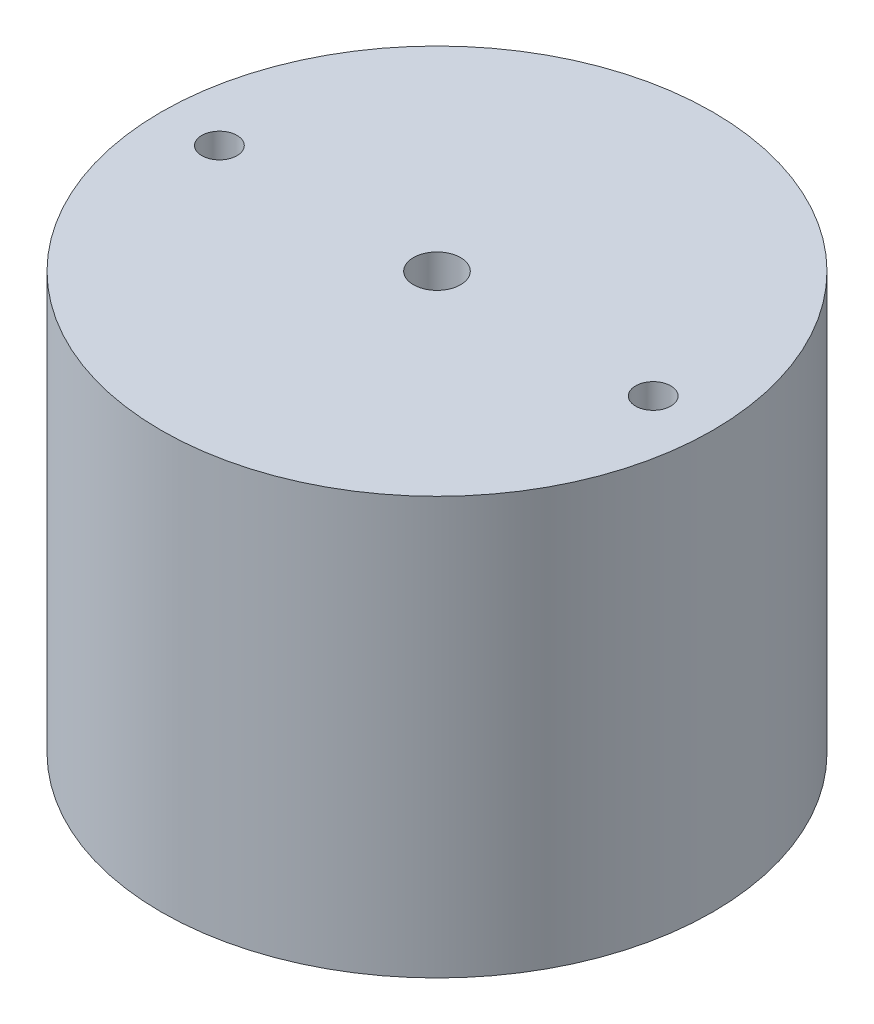
from build123d import *

# Parameters (mm, degrees)
SKETCH1_R           = 75.565
SKETCH1_R_2         = 6.460434783
SKETCH1_R_3         = 4.826
BOSS_EXTRUDE1_DEPTH = 57.15


with BuildPart() as part:
    # Sketch1 → Boss-Extrude1 (new body, symmetric)
    with BuildSketch(Plane(origin=(0, 0, 0), x_dir=(1, 0, 0), z_dir=(0, 1, 0))):
        Circle(SKETCH1_R)
        Circle(SKETCH1_R_2, mode=Mode.SUBTRACT)
        with Locations((-59.628113375, 0)):
            Circle(SKETCH1_R_3, mode=Mode.SUBTRACT)
        with Locations((59.243886625, 0)):
            Circle(SKETCH1_R_3, mode=Mode.SUBTRACT)
    extrude(amount=BOSS_EXTRUDE1_DEPTH, both=True)


solid = part.part
